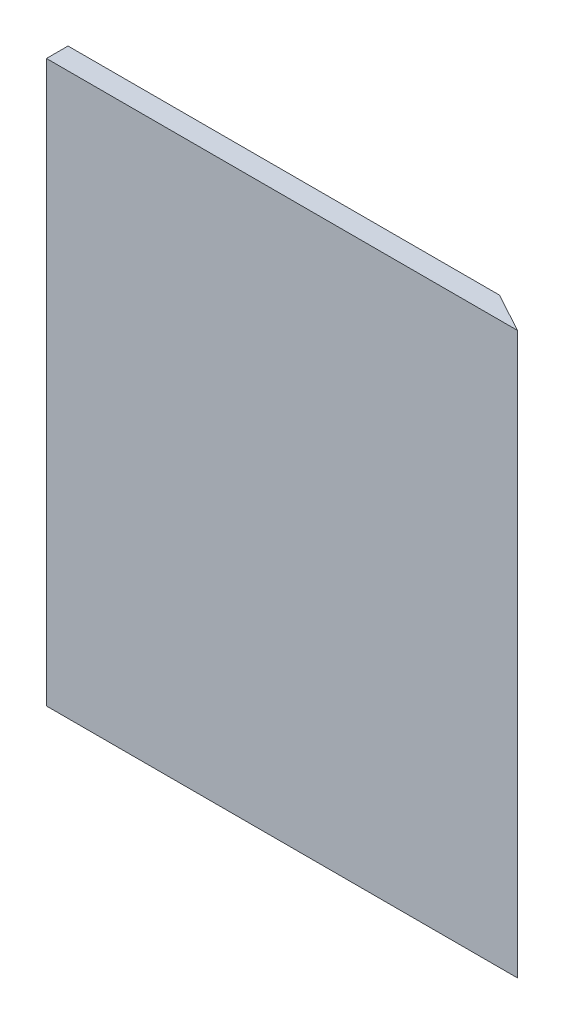
from build123d import *

# Parameters (mm, degrees)
BOSS_EXTRUDE2_DEPTH = 330.2


with BuildPart() as part:
    # Sketch1 → Boss-Extrude2 (new body)
    with BuildSketch(Plane(origin=(0, 0, 0), x_dir=(1, 0, 0), z_dir=(0, 1, 0))):
        Polygon((185.28744488, 75.471040866), (208.672103133, 62.771040866), (185.28744488, 62.771040866), (-68.71255512, 62.771040866), (-68.71255512, 75.471040866), align=None)
    extrude(amount=BOSS_EXTRUDE2_DEPTH)


solid = part.part
